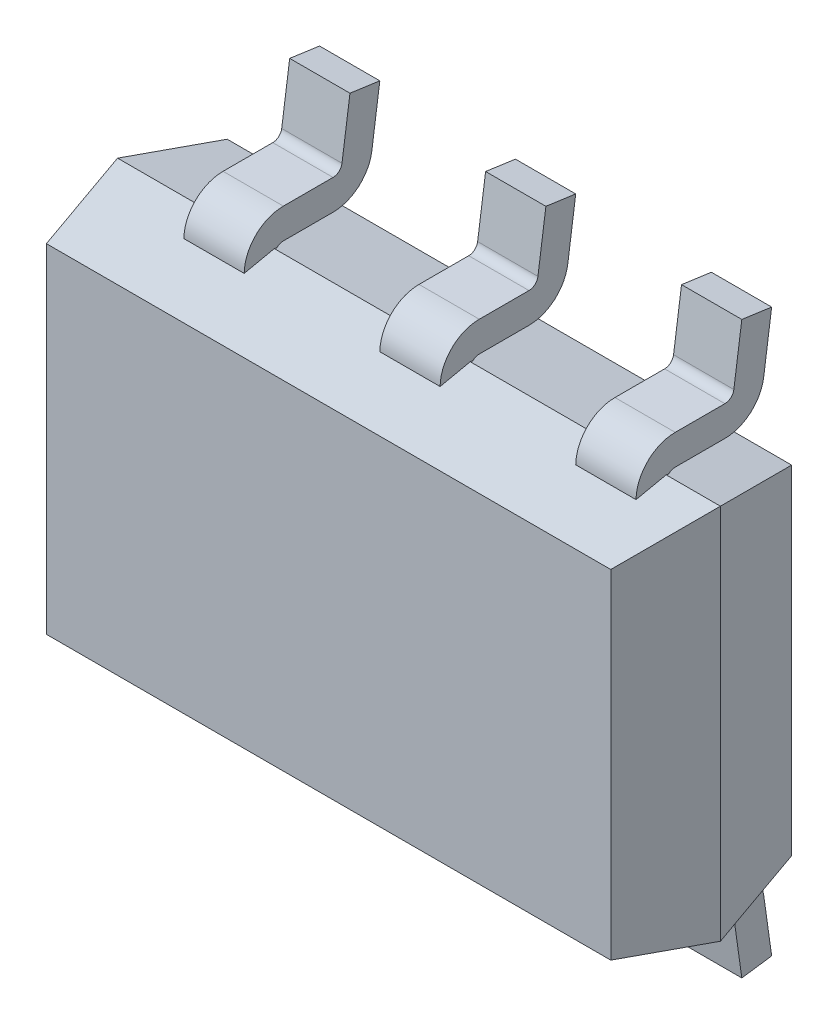
from build123d import *

# Parameters (mm, degrees)
SKETCH1_W            = 2
SKETCH1_H            = 1.25
BOSS_EXTRUDE1_DEPTH  = 0.3
BOSS_EXTRUDE1_TAPER  = 12
SKETCH2_W            = 2
SKETCH2_H            = 1.25
BOSS_EXTRUDE2_DEPTH  = 0.3
BOSS_EXTRUDE2_TAPER  = 12
EXTRUDE_THIN1_DEPTH  = 0.1
LPATTERN1_COUNT      = 3
LPATTERN1_PITCH      = 0.65
MIRROR1_COPY_1_DEPTH = 0.1
LPATTERN2_COUNT      = 2
LPATTERN2_PITCH      = 0.65


with BuildPart() as part:
    # Sketch1 → Boss-Extrude1 (new body)
    with BuildSketch(Plane.XY):
        with Locations((1, 0.625)):
            Rectangle(SKETCH1_W, SKETCH1_H)
    extrude(amount=BOSS_EXTRUDE1_DEPTH, taper=BOSS_EXTRUDE1_TAPER)

    # Sketch2 → Boss-Extrude2 (add)
    with BuildSketch(Plane(origin=(0, 0, 0), x_dir=(-1, 0, 0), z_dir=(0, 0, -1))):
        with Locations((-1, 0.625)):
            Rectangle(SKETCH2_W, SKETCH2_H)
    extrude(amount=BOSS_EXTRUDE2_DEPTH, taper=BOSS_EXTRUDE2_TAPER)

    # Sketch4 → Extrude-Thin1 (add, symmetric)
    with BuildSketch(Plane(origin=(0.42, 0, 0), x_dir=(0, 0, -1), z_dir=(1, 0, 0))):
        with BuildLine():
            Line((0, 1.218116516), (0, 1.227154368))
            ThreePointArc((0, 1.227154368), (0.008786797, 1.248367571), (0.03, 1.257154368))
            Line((0.03, 1.257154368), (0.194830474, 1.257154368))
            ThreePointArc((0.194830474, 1.257154368), (0.280118147, 1.289042122), (0.323565323, 1.369061865))
            Line((0.323565323, 1.369061865), (0.35, 1.557154368))
            Line((0.35, 1.557154368), (0.250973193, 1.571071678))
            Line((0.250973193, 1.571071678), (0.224538516, 1.382979175))
            ThreePointArc((0.224538516, 1.382979175), (0.214512245, 1.36451308), (0.194830474, 1.357154368))
            Line((0.194830474, 1.357154368), (0.03, 1.357154368))
            ThreePointArc((0.03, 1.357154368), (-0.061923882, 1.319078249), (-0.1, 1.227154368))
            Line((-0.1, 1.227154368), (-0.1, 1.218116516))
            Line((-0.1, 1.218116516), (0, 1.218116516))
        make_face()
    extrude_thin1 = extrude(amount=EXTRUDE_THIN1_DEPTH, both=True)

    # LPattern1: Extrude-Thin1 ×3, 1 skipped
    with Locations(*[(i * LPATTERN1_PITCH, 0, 0) for i in range(1, LPATTERN1_COUNT) if i not in (1,)]):
        add(extrude_thin1)

    # Mirror1: Extrude-Thin1 across plane
    add(extrude_thin1.mirror(Plane.ZX.offset(0.625)))

    # Mirror1 copy 1 sketch → Mirror1 copy 1 (add, symmetric)
    with BuildSketch(Plane(origin=(1.72, 1.25, 0), x_dir=(0, 0, -1), z_dir=(1, 0, 0))):
        with BuildLine():
            Line((0, -1.218116516), (0, -1.227154368))
            ThreePointArc((0, -1.227154368), (0.008786797, -1.248367571), (0.03, -1.257154368))
            Line((0.03, -1.257154368), (0.194830474, -1.257154368))
            ThreePointArc((0.194830474, -1.257154368), (0.280118147, -1.289042122), (0.323565323, -1.369061865))
            Line((0.323565323, -1.369061865), (0.35, -1.557154368))
            Line((0.35, -1.557154368), (0.250973193, -1.571071678))
            Line((0.250973193, -1.571071678), (0.224538516, -1.382979175))
            ThreePointArc((0.224538516, -1.382979175), (0.214512245, -1.36451308), (0.194830474, -1.357154368))
            Line((0.194830474, -1.357154368), (0.03, -1.357154368))
            ThreePointArc((0.03, -1.357154368), (-0.061923882, -1.319078249), (-0.1, -1.227154368))
            Line((-0.1, -1.227154368), (-0.1, -1.218116516))
            Line((-0.1, -1.218116516), (0, -1.218116516))
        make_face()
    extrude(amount=MIRROR1_COPY_1_DEPTH, both=True)

    # LPattern2: Extrude-Thin1 ×2
    with Locations(*[(i * LPATTERN2_PITCH, 0, 0) for i in range(1, LPATTERN2_COUNT)]):
        add(extrude_thin1)


solid = part.part
